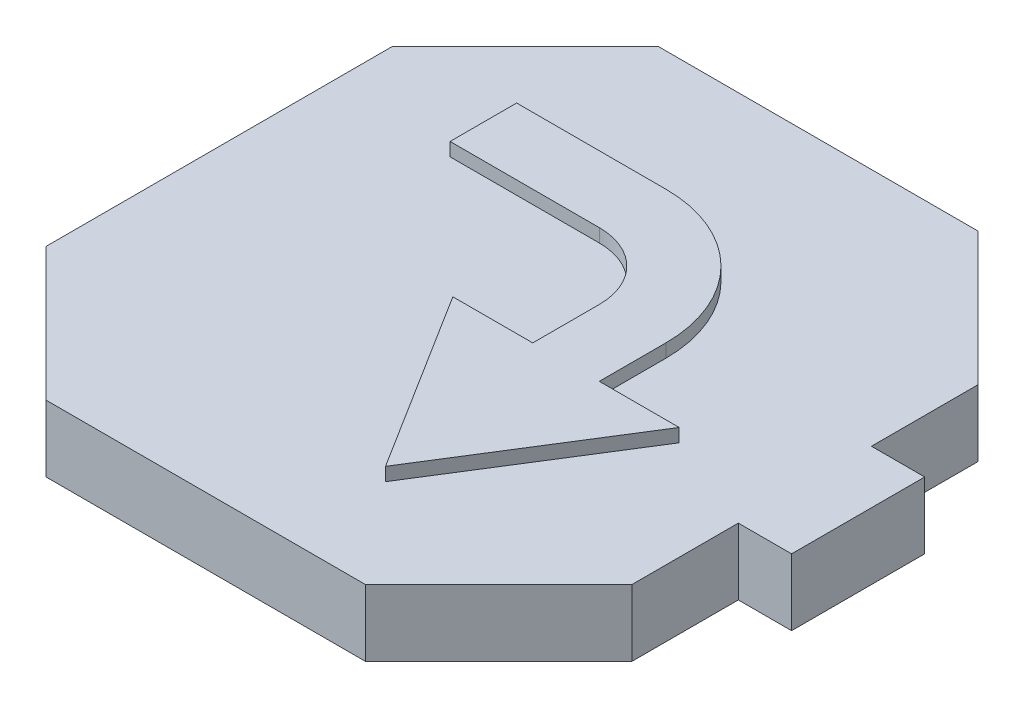
from build123d import *

# Parameters (mm, degrees)
BOSS_EXTRU_1_DEPTH      = 5
BOSS_EXTRU_2_DEPTH      = 1
ESQUISSE3_W             = 5.2
ESQUISSE3_H             = 5.2
ESQUISSE3_W_2           = 5
ESQUISSE3_H_2           = 5
ENL_V_MAT_EXTRU_1_DEPTH = 4.8
CONG_1_R                = 10
CONG_2_R                = 5


with BuildPart() as part:
    # Esquisse1 → Boss.-Extru.1 (new body)
    with BuildSketch(Plane(origin=(0, 0, 0), x_dir=(1, 0, 0), z_dir=(0, 1, 0))):
        Polygon((22, 13), (12.003020456, 23), (-12.003020456, 23), (-22, 13), (-22, -13), (-12.003020456, -23), (12.003020456, -23), (22, -13), (22, -5), (26, -5), (26, 5), (22, 5), align=None)
    extrude(amount=BOSS_EXTRU_1_DEPTH)

    # Esquisse2 → Boss.-Extru.2 (add)
    with BuildSketch(Plane(origin=(0, 5, 0), x_dir=(1, 0, 0), z_dir=(0, 1, 0))):
        Polygon((-12.651968736, 13), (-12.651968736, 8), (3.556100985, 8), (3.556100985, -2), (-2.443899015, -2), (6.056100985, -15.555441712), (14.556100985, -2), (8.556100985, -2), (8.556100985, 13), align=None)
    extrude(amount=BOSS_EXTRU_2_DEPTH)

    # Esquisse3 → Enlèv. mat.-Extru.1 (cut)
    with BuildSketch(Plane.XZ):
        with Locations((-13.4, 14.4)):
            Rectangle(ESQUISSE3_W, ESQUISSE3_H)
        with Locations((-13.4, -14.4)):
            Rectangle(ESQUISSE3_W, ESQUISSE3_H)
        with Locations((14.4, -14.4)):
            Rectangle(ESQUISSE3_W, ESQUISSE3_H)
        with Locations((13.4, 14.4)):
            Rectangle(ESQUISSE3_W, ESQUISSE3_H)
        Rectangle(ESQUISSE3_W_2, ESQUISSE3_H_2)
    extrude(amount=-ENL_V_MAT_EXTRU_1_DEPTH, mode=Mode.SUBTRACT)

    # Congé1
    cong_1_edges = [part.edges().sort_by_distance(p)[0] for p in [
        (8.556100985, 5.5, -13),
    ]]
    fillet(cong_1_edges, radius=CONG_1_R)

    # Congé2
    cong_2_edges = [part.edges().sort_by_distance(p)[0] for p in [
        (3.556100985, 5.5, -8),
    ]]
    fillet(cong_2_edges, radius=CONG_2_R)


solid = part.part
